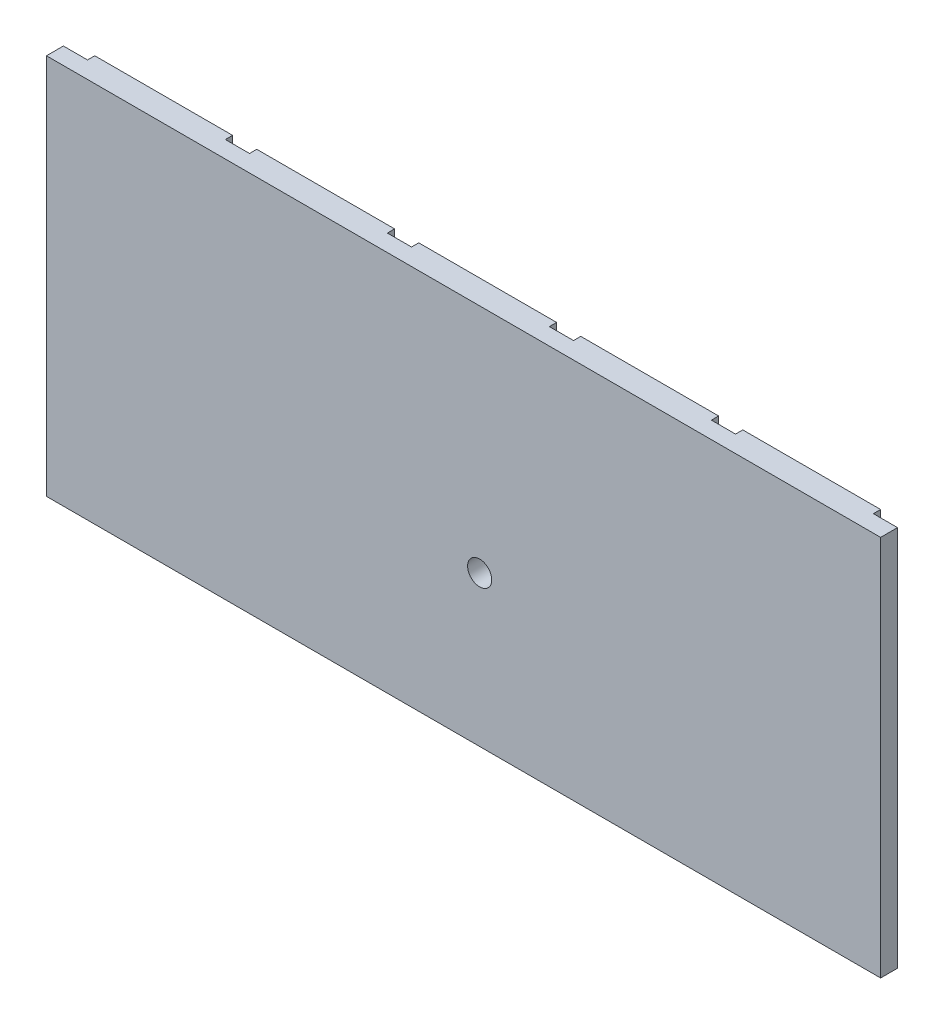
from build123d import *

# Parameters (mm, degrees)
SKETCH1_W           = 172.688303012
SKETCH1_H           = 79
SKETCH1_R           = 2.5
BOSS_EXTRUDE1_DEPTH = 5
CUT_EXTRUDE1_REACH  = 81
SKETCH2_W           = 5
SKETCH2_H           = 1.5


with BuildPart() as part:
    # Sketch1 → Boss-Extrude1 (new body)
    with BuildSketch(Plane.XY):
        Rectangle(SKETCH1_W, SKETCH1_H)
        with Locations((3.337204705, -8.386778216)):
            Circle(SKETCH1_R, mode=Mode.SUBTRACT)
    extrude(amount=BOSS_EXTRUDE1_DEPTH)

    # Sketch2 → Cut-Extrude1 (cut, up to next)
    with BuildSketch(Plane(origin=(0, 39.5, 0), x_dir=(1, 0, 0), z_dir=(0, 1, 0)), mode=Mode.PRIVATE) as cut_extrude1_sk1:
        with Locations((83.844151506, -0.75)):
            Rectangle(SKETCH2_W, SKETCH2_H)
    cut_extrude1_tool1 = extrude(cut_extrude1_sk1.sketch, amount=-CUT_EXTRUDE1_REACH, mode=Mode.PRIVATE) & part.part
    add(cut_extrude1_tool1.solids().sort_by_distance((83.844152, 39.5, 0.75))[0], mode=Mode.SUBTRACT)
    # Sketch2 → Cut-Extrude1 (cut, up to next)
    with BuildSketch(Plane(origin=(0, 39.5, 0), x_dir=(1, 0, 0), z_dir=(0, 1, 0)), mode=Mode.PRIVATE) as cut_extrude1_sk2:
        with Locations((50.306490903, -0.75)):
            Rectangle(SKETCH2_W, SKETCH2_H)
    cut_extrude1_tool2 = extrude(cut_extrude1_sk2.sketch, amount=-CUT_EXTRUDE1_REACH, mode=Mode.PRIVATE) & part.part
    add(cut_extrude1_tool2.solids().sort_by_distance((50.306491, 39.5, 0.75))[0], mode=Mode.SUBTRACT)
    # Sketch2 → Cut-Extrude1 (cut, up to next)
    with BuildSketch(Plane(origin=(0, 39.5, 0), x_dir=(1, 0, 0), z_dir=(0, 1, 0)), mode=Mode.PRIVATE) as cut_extrude1_sk3:
        with Locations((16.768830301, -0.75)):
            Rectangle(SKETCH2_W, SKETCH2_H)
    cut_extrude1_tool3 = extrude(cut_extrude1_sk3.sketch, amount=-CUT_EXTRUDE1_REACH, mode=Mode.PRIVATE) & part.part
    add(cut_extrude1_tool3.solids().sort_by_distance((16.76883, 39.5, 0.75))[0], mode=Mode.SUBTRACT)
    # Sketch2 → Cut-Extrude1 (cut, up to next)
    with BuildSketch(Plane(origin=(0, 39.5, 0), x_dir=(1, 0, 0), z_dir=(0, 1, 0)), mode=Mode.PRIVATE) as cut_extrude1_sk4:
        with Locations((-16.768830301, -0.75)):
            Rectangle(SKETCH2_W, SKETCH2_H)
    cut_extrude1_tool4 = extrude(cut_extrude1_sk4.sketch, amount=-CUT_EXTRUDE1_REACH, mode=Mode.PRIVATE) & part.part
    add(cut_extrude1_tool4.solids().sort_by_distance((-16.76883, 39.5, 0.75))[0], mode=Mode.SUBTRACT)
    # Sketch2 → Cut-Extrude1 (cut, up to next)
    with BuildSketch(Plane(origin=(0, 39.5, 0), x_dir=(1, 0, 0), z_dir=(0, 1, 0)), mode=Mode.PRIVATE) as cut_extrude1_sk5:
        with Locations((-50.306490903, -0.75)):
            Rectangle(SKETCH2_W, SKETCH2_H)
    cut_extrude1_tool5 = extrude(cut_extrude1_sk5.sketch, amount=-CUT_EXTRUDE1_REACH, mode=Mode.PRIVATE) & part.part
    add(cut_extrude1_tool5.solids().sort_by_distance((-50.306491, 39.5, 0.75))[0], mode=Mode.SUBTRACT)
    # Sketch2 → Cut-Extrude1 (cut, up to next)
    with BuildSketch(Plane(origin=(0, 39.5, 0), x_dir=(1, 0, 0), z_dir=(0, 1, 0)), mode=Mode.PRIVATE) as cut_extrude1_sk6:
        with Locations((-83.844151506, -0.75)):
            Rectangle(SKETCH2_W, SKETCH2_H)
    cut_extrude1_tool6 = extrude(cut_extrude1_sk6.sketch, amount=-CUT_EXTRUDE1_REACH, mode=Mode.PRIVATE) & part.part
    add(cut_extrude1_tool6.solids().sort_by_distance((-83.844152, 39.5, 0.75))[0], mode=Mode.SUBTRACT)


solid = part.part
